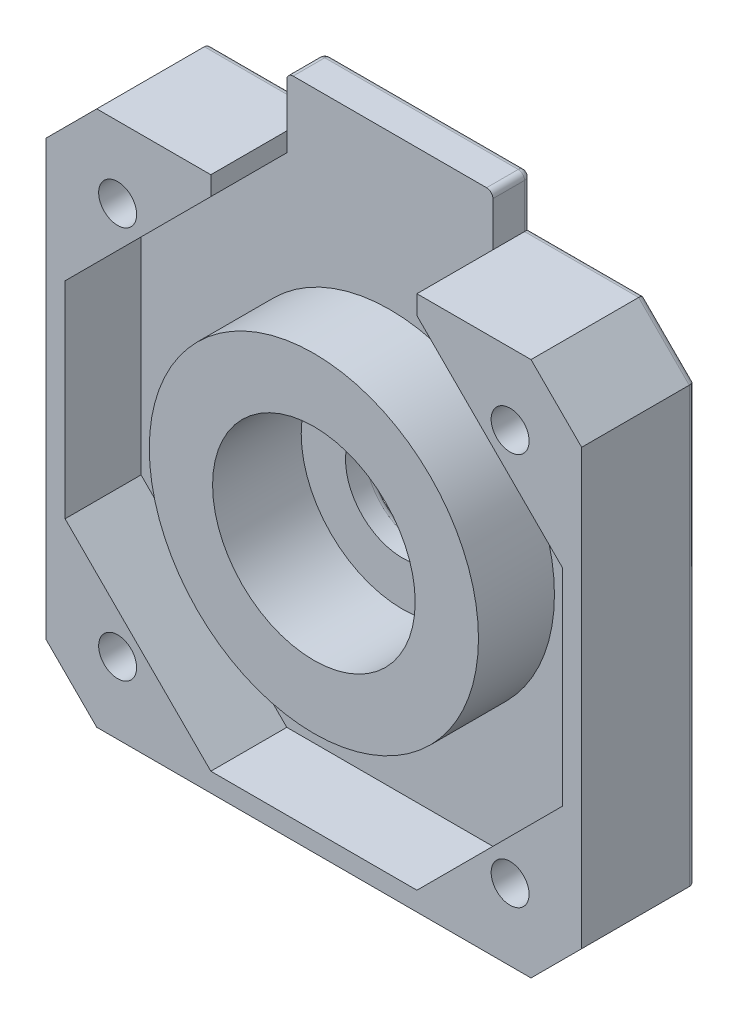
from build123d import *

# Parameters (mm, degrees)
BOSS_EXTRUDE1_DEPTH = 9
SKETCH9_R           = 13
CUT_EXTRUDE6_DEPTH  = 6
SKETCH10_R          = 8
CUT_EXTRUDE7_DEPTH  = 7
SKETCH11_R          = 4.5
CUT_EXTRUDE8_DEPTH  = 3
SKETCH13_R          = 1.5
CUT_EXTRUDE9_DEPTH  = 10
SKETCH14_R          = 3.1
CUT_EXTRUDE11_DEPTH = 2.5
SKETCH15_W          = 16.278593002
SKETCH15_H          = 3
BOSS_EXTRUDE3_DEPTH = 4
FILLET4_R           = 0.5


with BuildPart() as part:
    # Sketch2 → Boss-Extrude1 (new body)
    with BuildSketch(Plane.XY):
        Polygon((-21.15, 17.15), (-17.15, 21.15), (17.15, 21.15), (21.15, 17.15), (21.15, -17.15), (17.15, -21.15), (-17.15, -21.15), (-21.15, -17.15), align=None)
    extrude(amount=BOSS_EXTRUDE1_DEPTH)

    # Sketch9 → Cut-Extrude6 (cut)
    with BuildSketch(Plane.XY.offset(9)):
        Polygon((-8.139296501, 19.65), (-19.65, 8.139296501), (-19.65, -8.139296501), (-8.139296501, -19.65), (8.139296501, -19.65), (19.65, -8.139296501), (19.65, 8.139296501), (8.139296501, 19.65), (8.139296501, 21.15), (-8.139296501, 21.15), align=None)
        Circle(SKETCH9_R, mode=Mode.SUBTRACT)
    extrude(amount=-CUT_EXTRUDE6_DEPTH, mode=Mode.SUBTRACT)

    # Sketch10 → Cut-Extrude7 (cut)
    with BuildSketch(Plane.XY.offset(9)):
        Circle(SKETCH10_R)
    extrude(amount=-CUT_EXTRUDE7_DEPTH, mode=Mode.SUBTRACT)

    # Sketch11 → Cut-Extrude8 (cut, through all)
    with BuildSketch(Plane.XY.offset(2)):
        Circle(SKETCH11_R)
    extrude(amount=-CUT_EXTRUDE8_DEPTH, mode=Mode.SUBTRACT)

    # Sketch13 → Cut-Extrude9 (cut, through all)
    with BuildSketch(Plane.XY.offset(9)):
        with Locations((-15.5, -15.5)):
            Circle(SKETCH13_R)
        with Locations((-15.5, 15.5)):
            Circle(SKETCH13_R)
        with Locations((15.5, 15.5)):
            Circle(SKETCH13_R)
        with Locations((15.5, -15.5)):
            Circle(SKETCH13_R)
    extrude(amount=-CUT_EXTRUDE9_DEPTH, mode=Mode.SUBTRACT)

    # Sketch14 → Cut-Extrude11 (cut)
    with BuildSketch(Plane(origin=(0, 0, 0), x_dir=(-1, 0, 0), z_dir=(0, 0, -1))):
        with Locations((-15.5, 15.5)):
            Circle(SKETCH14_R)
        with Locations((15.5, 15.5)):
            Circle(SKETCH14_R)
        with Locations((-15.5, -15.5)):
            Circle(SKETCH14_R)
        with Locations((15.5, -15.5)):
            Circle(SKETCH14_R)
    extrude(amount=-CUT_EXTRUDE11_DEPTH, mode=Mode.SUBTRACT)

    # Sketch15 → Boss-Extrude3 (add)
    with BuildSketch(Plane(origin=(0, 21.15, 0), x_dir=(1, 0, 0), z_dir=(0, 1, 0))):
        with Locations((0, -1.5)):
            Rectangle(SKETCH15_W, SKETCH15_H)
    extrude(amount=BOSS_EXTRUDE3_DEPTH)

    # Fillet4
    fillet4_edges = [part.edges().sort_by_distance(p)[0] for p in [
        (-19.15, -19.15, 0),
        (-21.15, 0, 0),
        (-12.64464825, 21.15, 0),
        (-8.139296501, 23.15, 0),
        (8.139296501, 23.15, 0),
        (-8.139296501, 25.15, 1.5),
        (8.139296501, 25.15, 1.5),
        (0, 25.15, 0),
        (-4.5, 0, 0),
        (-19.15, 19.15, 0),
        (12.64464825, 21.15, 0),
        (19.15, 19.15, 0),
        (-12.4, 15.5, 0),
        (21.15, 0, 0),
        (18.6, -15.5, 0),
        (-12.4, -15.5, 0),
        (19.15, -19.15, 0),
        (18.6, 15.5, 0),
        (0, -21.15, 0),
    ]]
    fillet(fillet4_edges, radius=FILLET4_R)


solid = part.part
